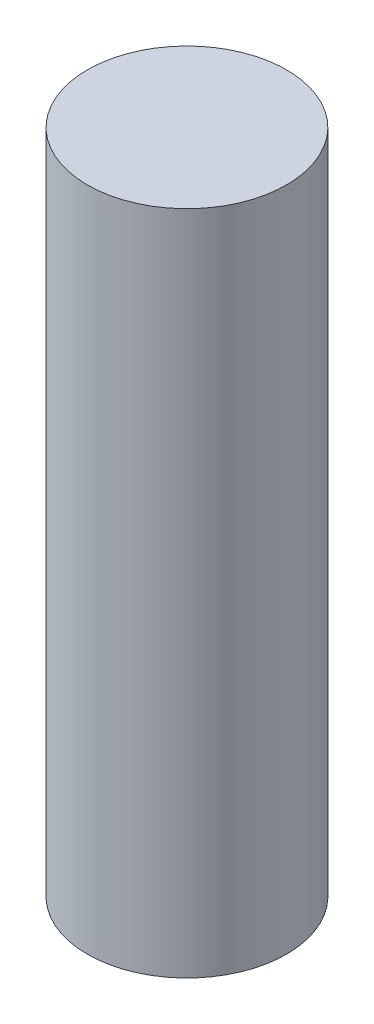
from build123d import *

# Parameters (mm, degrees)
SKETCH1_R           = 5
BOSS_EXTRUDE1_DEPTH = 33.43


with BuildPart() as part:
    # Sketch1 → Boss-Extrude1 (new body)
    with BuildSketch(Plane(origin=(0, 0, 0), x_dir=(1, 0, 0), z_dir=(0, 1, 0))):
        Circle(SKETCH1_R)
    extrude(amount=BOSS_EXTRUDE1_DEPTH)


solid = part.part
